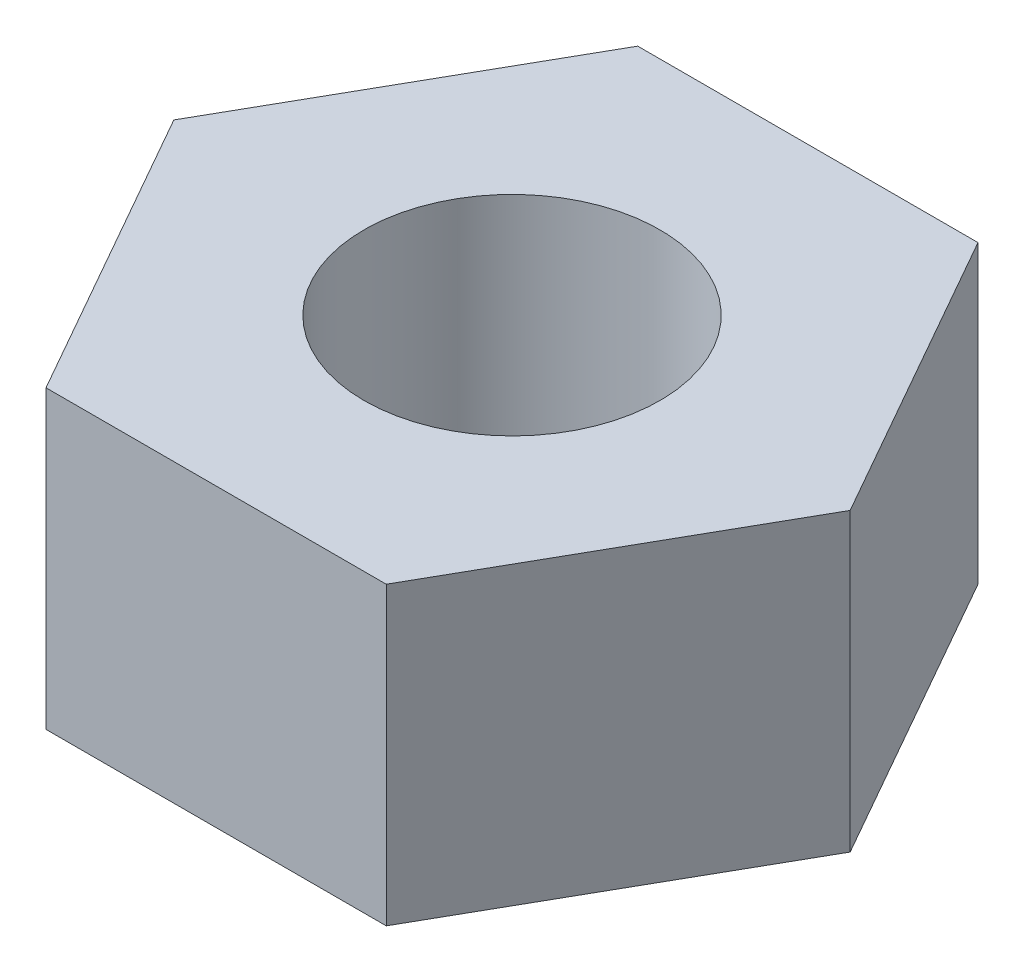
from build123d import *

# Parameters (mm, degrees)
SKETCH1_R           = 5
BOSS_EXTRUDE1_DEPTH = 10


with BuildPart() as part:
    # Sketch1 → Boss-Extrude1 (new body)
    with BuildSketch(Plane(origin=(0, 0, 0), x_dir=(1, 0, 0), z_dir=(0, 1, 0))):
        Polygon((-5.75, 10), (5.75, 10), (11.428908346, 0), (5.75, -10), (-5.75, -10), (-11.428908346, 0), align=None)
        Circle(SKETCH1_R, mode=Mode.SUBTRACT)
    extrude(amount=BOSS_EXTRUDE1_DEPTH)


solid = part.part
